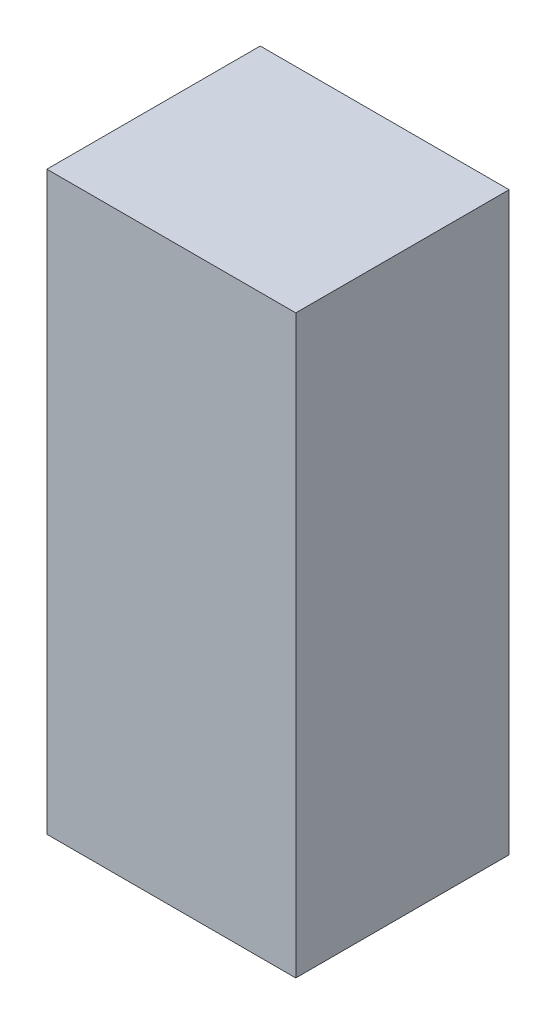
from build123d import *

# Parameters (mm, degrees)
SKETCH1_W           = 175
SKETCH1_H           = 150
BOSS_EXTRUDE1_DEPTH = 405


with BuildPart() as part:
    # Sketch1 → Boss-Extrude1 (new body)
    with BuildSketch(Plane(origin=(0, 0, 0), x_dir=(1, 0, 0), z_dir=(0, 1, 0))):
        with Locations((87.5, 75)):
            Rectangle(SKETCH1_W, SKETCH1_H)
    extrude(amount=BOSS_EXTRUDE1_DEPTH)


solid = part.part
